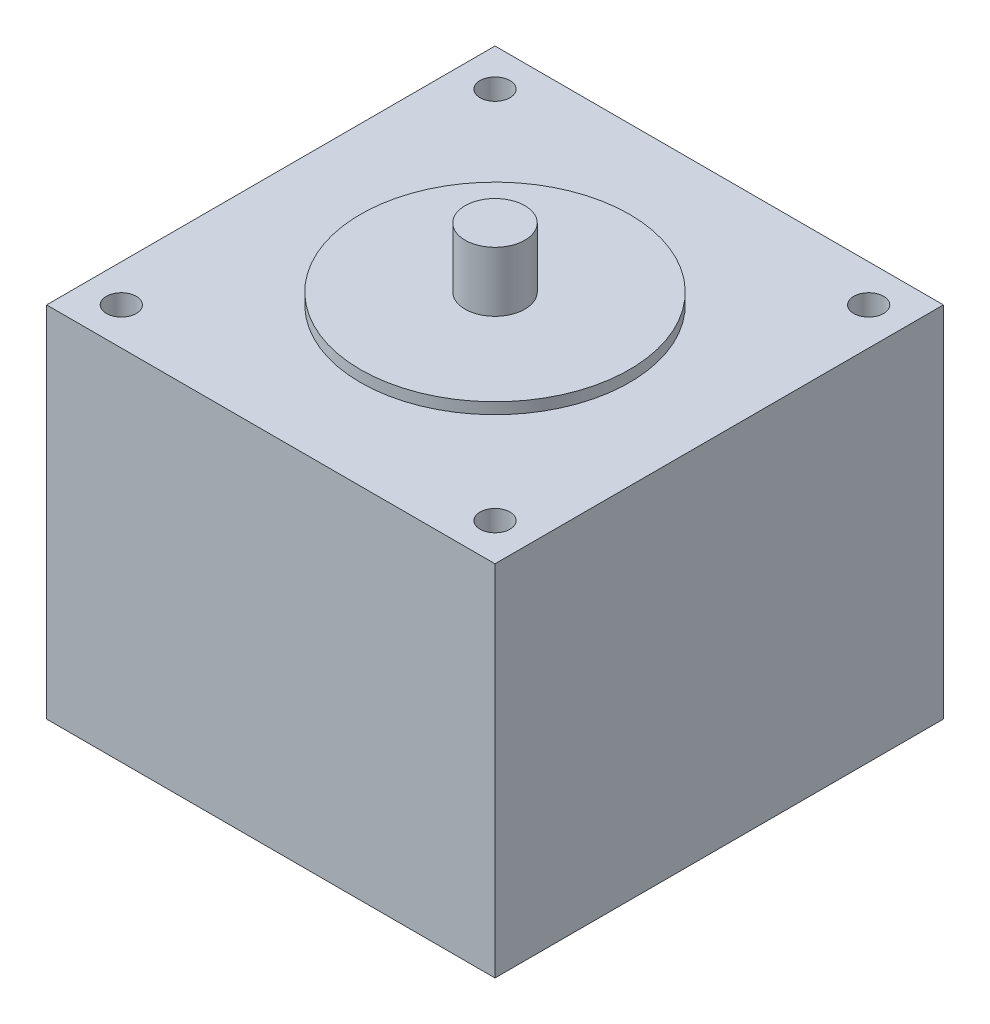
from build123d import *

# Parameters (mm, degrees)
SKETCH1_W           = 60
SKETCH1_H           = 60
SKETCH1_R           = 2
BOSS_EXTRUDE1_DEPTH = 48


with BuildPart() as part:
    # Sketch1 → Boss-Extrude1 (new body)
    with BuildSketch(Plane(origin=(0, 0, 0), x_dir=(1, 0, 0), z_dir=(0, 1, 0))):
        Rectangle(SKETCH1_W, SKETCH1_H)
        with Locations((-25, 25)):
            Circle(SKETCH1_R, mode=Mode.SUBTRACT)
        with Locations((25, 25)):
            Circle(SKETCH1_R, mode=Mode.SUBTRACT)
        with Locations((25, -25)):
            Circle(SKETCH1_R, mode=Mode.SUBTRACT)
        with Locations((-25, -25)):
            Circle(SKETCH1_R, mode=Mode.SUBTRACT)
    extrude(amount=BOSS_EXTRUDE1_DEPTH)

    # Sketch3 → Revolve1 (revolve)
    with BuildSketch(Plane.XY):
        Polygon((0, 48), (18, 48), (18, 49.5), (4, 49.5), (4, 57.5), (0, 57.5), align=None)
    revolve(axis=Axis((0, 57.5, 0), (0, -1, 0)))


solid = part.part
